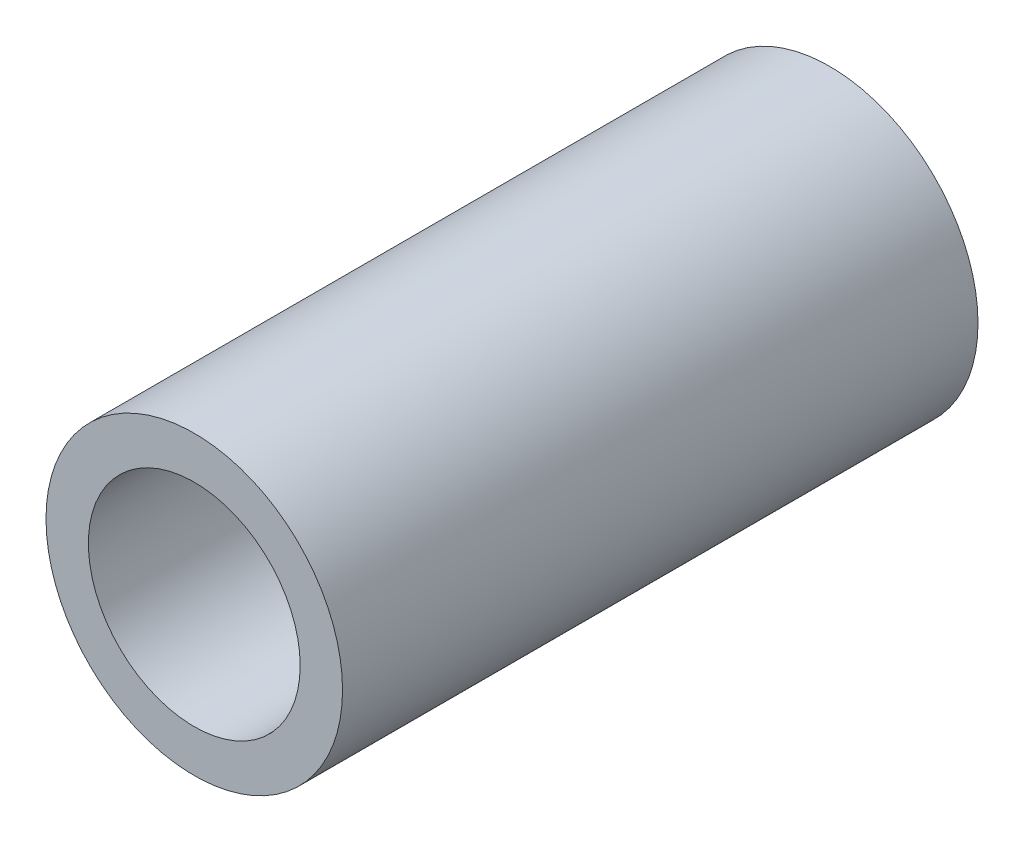
from build123d import *

# Parameters (mm, degrees)
SKETCH1_R           = 3.5
SKETCH1_R_2         = 2.5
BOSS_EXTRUDE1_DEPTH = 15


with BuildPart() as part:
    # Sketch1 → Boss-Extrude1 (new body)
    with BuildSketch(Plane.XY):
        Circle(SKETCH1_R)
        Circle(SKETCH1_R_2, mode=Mode.SUBTRACT)
    extrude(amount=BOSS_EXTRUDE1_DEPTH)


solid = part.part
